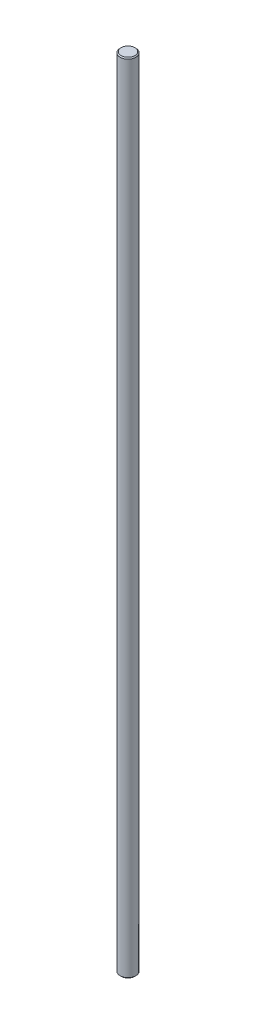
from build123d import *

# Parameters (mm, degrees)
SKETCH1_R           = 4
BOSS_EXTRUDE1_DEPTH = 406.4
CHAMFER1_SIZE       = 0.5


with BuildPart() as part:
    # Sketch1 → Boss-Extrude1 (new body)
    with BuildSketch(Plane(origin=(0, 0, 0), x_dir=(1, 0, 0), z_dir=(0, 1, 0))):
        Circle(SKETCH1_R)
    extrude(amount=BOSS_EXTRUDE1_DEPTH)

    # Chamfer1
    chamfer1_edges = [part.edges().sort_by_distance(p)[0] for p in [
        (-4, 0, 0),
        (-4, 406.4, 0),
    ]]
    chamfer(chamfer1_edges, length=CHAMFER1_SIZE)


solid = part.part
